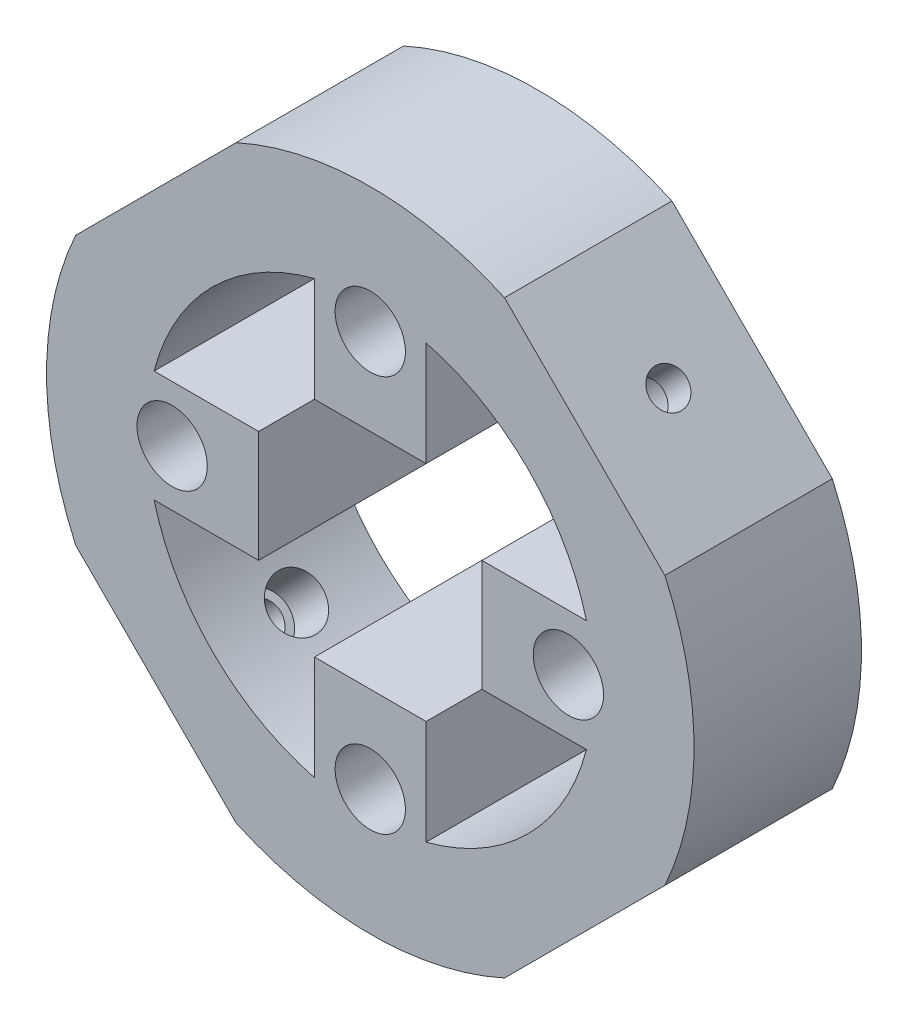
from build123d import *

# Parameters (mm, degrees)
SKETCH6_R                 = 29
SKETCH6_R_2               = 20
INNER_RING_DEPTH          = 15
MOTOR_CONNECTOR_CUT_DEPTH = 15
SKETCH10_R                = 3.15
CUT_EXTRUDE2_DEPTH        = 55
CUT_EXTRUDE2_DEPTH_BACK   = 70
CUT_EXTRUDE4_DEPTH        = 22
CUT_EXTRUDE6_DEPTH        = 7.9
CUT_EXTRUDE5_DEPTH        = 22
SKETCH15_R                = 2.35
SKETCH15_R_2              = 1.65
BOSS_EXTRUDE1_DEPTH       = 2.9
BOSS_EXTRUDE3_DEPTH       = 2.9
CUT_EXTRUDE8_DEPTH        = 9.9
CUT_EXTRUDE7_DEPTH        = 8.9
SKETCH21_R                = 2.35
SKETCH21_R_2              = 1.65
BOSS_EXTRUDE5_DEPTH       = 2.9
SKETCH19_R                = 2.35
SKETCH19_R_2              = 1.65
BOSS_EXTRUDE4_DEPTH       = 2.9


with BuildPart() as part:
    # Sketch6 → Inner Ring (new body)
    with BuildSketch(Plane.XY):
        Circle(SKETCH6_R)
        Circle(SKETCH6_R_2, mode=Mode.SUBTRACT)
    extrude(amount=-INNER_RING_DEPTH)

    # Sketch7 → Motor Connector Cut (add)
    with BuildSketch(Plane.XY):
        with BuildLine():
            ThreePointArc((20, 0), (19.840593925, 2.52008585), (19.364916731, 5))
            Line((19.364916731, 5), (9.999996731, 5))
            Line((9.999996731, 5), (9.999996731, -5))
            Line((9.999996731, -5), (19.364916731, -5))
            ThreePointArc((19.364916731, -5), (19.840593925, -2.52008585), (20, 0))
        make_face()
        with BuildLine():
            ThreePointArc((5, 19.364916731), (0, 20), (-5, 19.364916731))
            Line((-5, 19.364916731), (-5, 9.999996731))
            Line((-5, 9.999996731), (5, 9.999996731))
            Line((5, 9.999996731), (5, 19.364916731))
        make_face()
        with BuildLine():
            Line((-9.999996731, -5), (-9.999996731, 5))
            Line((-9.999996731, 5), (-19.364916731, 5))
            ThreePointArc((-19.364916731, 5), (-20, 0), (-19.364916731, -5))
            Line((-19.364916731, -5), (-9.999996731, -5))
        make_face()
        with BuildLine():
            Line((-5, -9.999996731), (-5, -19.364916731))
            ThreePointArc((-5, -19.364916731), (0, -20), (5, -19.364916731))
            Line((5, -19.364916731), (5, -9.999996731))
            Line((5, -9.999996731), (-5, -9.999996731))
        make_face()
    extrude(amount=-MOTOR_CONNECTOR_CUT_DEPTH)

    # Sketch10 → Cut-Extrude2 (cut, two sides)
    with BuildSketch(Plane(origin=(0, 0, -15), x_dir=(-1, 0, 0), z_dir=(0, 0, -1))) as cut_extrude2_sk:
        with Locations((-17.75, 0)):
            Circle(SKETCH10_R)
        with Locations((0, 17.75)):
            Circle(SKETCH10_R)
        with Locations((17.75, 0)):
            Circle(SKETCH10_R)
        with Locations((0, -17.75)):
            Circle(SKETCH10_R)
    extrude(amount=CUT_EXTRUDE2_DEPTH, mode=Mode.SUBTRACT)
    extrude(cut_extrude2_sk.sketch, amount=-CUT_EXTRUDE2_DEPTH_BACK, mode=Mode.SUBTRACT)

    # Sketch9 → Cut-Extrude4 (cut)
    with BuildSketch(Plane(origin=(0, 0, -15), x_dir=(-1, 0, 0), z_dir=(0, 0, -1))):
        with BuildLine():
            Line((-26.38954799, 12.024631259), (-12.024631259, 26.38954799))
            ThreePointArc((-12.024631259, 26.38954799), (-20.506096654, 20.506096654), (-26.38954799, 12.024631259))
        make_face()
        with BuildLine():
            ThreePointArc((26.38954799, 12.024631259), (20.506096654, 20.506096654), (12.024631259, 26.38954799))
            Line((12.024631259, 26.38954799), (26.38954799, 12.024631259))
        make_face()
        with BuildLine():
            Line((-12.024631259, -26.38954799), (-26.38954799, -12.024631259))
            ThreePointArc((-26.38954799, -12.024631259), (-20.506096654, -20.506096654), (-12.024631259, -26.38954799))
        make_face()
        with BuildLine():
            Line((26.38954799, -12.024631259), (12.024631259, -26.38954799))
            ThreePointArc((12.024631259, -26.38954799), (20.506096654, -20.506096654), (26.38954799, -12.024631259))
        make_face()
    extrude(amount=-CUT_EXTRUDE4_DEPTH, mode=Mode.SUBTRACT)

    # Sketch16 → Cut-Extrude6 (cut)
    with BuildSketch(Plane(origin=(-19.207089624, 19.207089624, 0), x_dir=(0, 0, 1), z_dir=(-0.707106781, 0.707106781, 0))):
        with BuildLine():
            ThreePointArc((-5.15, 0), (-5.838299064, 1.661700936), (-7.5, 2.35))
            Line((-7.5, 2.35), (-7.5, -2.35))
            ThreePointArc((-7.5, -2.35), (-5.838299064, -1.661700936), (-5.15, 0))
        make_face()
        with BuildLine():
            Line((-7.5, -2.35), (-7.5, 2.35))
            ThreePointArc((-7.5, 2.35), (-9.85, 0), (-7.5, -2.35))
        make_face()
    extrude(amount=-CUT_EXTRUDE6_DEPTH, mode=Mode.SUBTRACT)

    # Sketch14 → Cut-Extrude5 (cut)
    with BuildSketch(Plane(origin=(19.207089624, 19.207089624, 0), x_dir=(0, 0, -1), z_dir=(0.707106781, 0.707106781, 0))):
        with BuildLine():
            ThreePointArc((9.85, 0), (9.161700936, 1.661700936), (7.5, 2.35))
            Line((7.5, 2.35), (7.5, -2.35))
            ThreePointArc((7.5, -2.35), (9.161700936, -1.661700936), (9.85, 0))
        make_face()
        with BuildLine():
            Line((7.5, -2.35), (7.5, 2.35))
            ThreePointArc((7.5, 2.35), (5.15, 0), (7.5, -2.35))
        make_face()
    extrude(amount=-CUT_EXTRUDE5_DEPTH, mode=Mode.SUBTRACT)

    # Sketch15 → Boss-Extrude1 (add)
    with BuildSketch(Plane(origin=(19.207089624, 19.207089624, 0), x_dir=(0, 0, -1), z_dir=(0.707106781, 0.707106781, 0))):
        with Locations((7.5, 0)):
            Circle(SKETCH15_R)
        with Locations((7.5, 0)):
            Circle(SKETCH15_R_2, mode=Mode.SUBTRACT)
    extrude(amount=-BOSS_EXTRUDE1_DEPTH)

    # Sketch17 → Boss-Extrude3 (add)
    with BuildSketch(Plane(origin=(-19.207089624, 19.207089624, 0), x_dir=(0, 0, 1), z_dir=(-0.707106781, 0.707106781, 0))):
        with BuildLine():
            ThreePointArc((-5.15, 0), (-5.838299064, 1.661700936), (-7.5, 2.35))
            Line((-7.5, 2.35), (-7.5, 1.65))
            ThreePointArc((-7.5, 1.65), (-6.333273811, 1.166726189), (-5.85, 0))
            ThreePointArc((-5.85, 0), (-6.333273811, -1.166726189), (-7.5, -1.65))
            Line((-7.5, -1.65), (-7.5, -2.35))
            ThreePointArc((-7.5, -2.35), (-5.838299064, -1.661700936), (-5.15, 0))
        make_face()
        with BuildLine():
            Line((-7.5, 1.65), (-7.5, 2.35))
            ThreePointArc((-7.5, 2.35), (-9.85, 0), (-7.5, -2.35))
            Line((-7.5, -2.35), (-7.5, -1.65))
            ThreePointArc((-7.5, -1.65), (-9.15, 0), (-7.5, 1.65))
        make_face()
    extrude(amount=-BOSS_EXTRUDE3_DEPTH)

    # Sketch20 → Cut-Extrude8 (cut)
    with BuildSketch(Plane(origin=(-19.207089624, -19.207089624, 0), x_dir=(0, 0, 1), z_dir=(-0.707106781, -0.707106781, 0))):
        with BuildLine():
            ThreePointArc((-5.15, 0), (-5.838299064, 1.661700936), (-7.5, 2.35))
            Line((-7.5, 2.35), (-7.5, -2.35))
            ThreePointArc((-7.5, -2.35), (-5.838299064, -1.661700936), (-5.15, 0))
        make_face()
        with BuildLine():
            Line((-7.5, -2.35), (-7.5, 2.35))
            ThreePointArc((-7.5, 2.35), (-9.85, 0), (-7.5, -2.35))
        make_face()
    extrude(amount=-CUT_EXTRUDE8_DEPTH, mode=Mode.SUBTRACT)

    # Sketch18 → Cut-Extrude7 (cut)
    with BuildSketch(Plane(origin=(19.207089624, -19.207089624, 0), x_dir=(0, 0, -1), z_dir=(0.707106781, -0.707106781, 0))):
        with BuildLine():
            ThreePointArc((9.85, 0), (9.161700936, 1.661700936), (7.5, 2.35))
            Line((7.5, 2.35), (7.5, -2.35))
            ThreePointArc((7.5, -2.35), (9.161700936, -1.661700936), (9.85, 0))
        make_face()
        with BuildLine():
            Line((7.5, -2.35), (7.5, 2.35))
            ThreePointArc((7.5, 2.35), (5.15, 0), (7.5, -2.35))
        make_face()
    extrude(amount=-CUT_EXTRUDE7_DEPTH, mode=Mode.SUBTRACT)

    # Sketch21 → Boss-Extrude5 (add)
    with BuildSketch(Plane(origin=(-19.207089624, -19.207089624, 0), x_dir=(0, 0, 1), z_dir=(-0.707106781, -0.707106781, 0))):
        with Locations((-7.5, 0)):
            Circle(SKETCH21_R)
        with Locations((-7.5, 0)):
            Circle(SKETCH21_R_2, mode=Mode.SUBTRACT)
    extrude(amount=-BOSS_EXTRUDE5_DEPTH)

    # Sketch19 → Boss-Extrude4 (add)
    with BuildSketch(Plane(origin=(19.207089624, -19.207089624, 0), x_dir=(0, 0, -1), z_dir=(0.707106781, -0.707106781, 0))):
        with Locations((7.5, 0)):
            Circle(SKETCH19_R)
        with Locations((7.5, 0)):
            Circle(SKETCH19_R_2, mode=Mode.SUBTRACT)
    extrude(amount=-BOSS_EXTRUDE4_DEPTH)


solid = part.part
